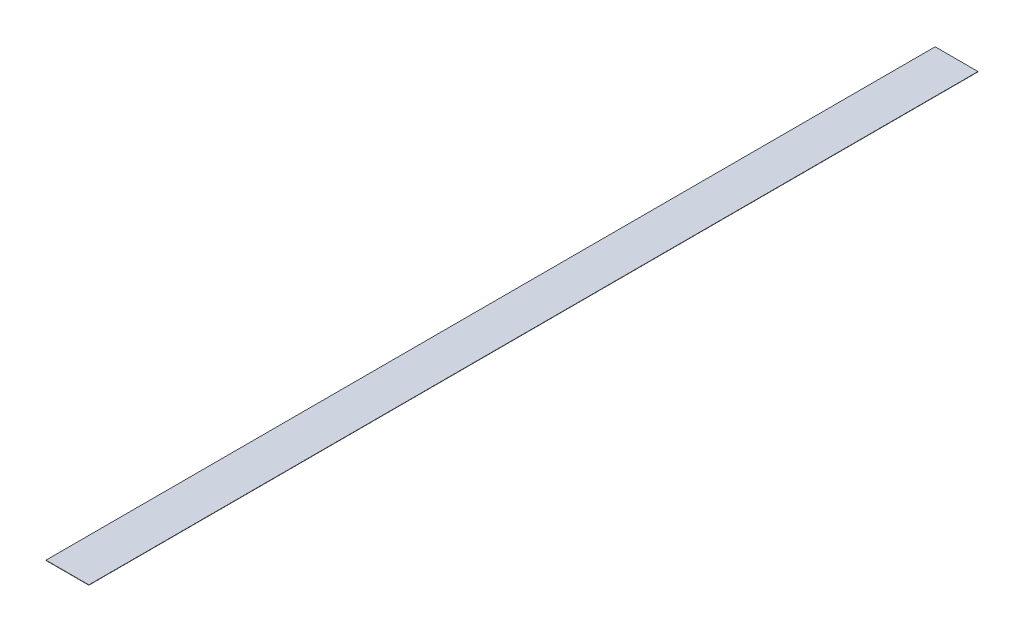
from build123d import *

# Parameters (mm, degrees)
SKETCH1_W      = 14.41
SKETCH1_H      = 299
EXTRUDE1_DEPTH = 0.1


with BuildPart() as part:
    # Sketch1 → Extrude1 (new body)
    with BuildSketch(Plane(origin=(0, 0, 0), x_dir=(1, 0, 0), z_dir=(0, 1, 0))):
        Rectangle(SKETCH1_W, SKETCH1_H)
    extrude(amount=EXTRUDE1_DEPTH)


solid = part.part
